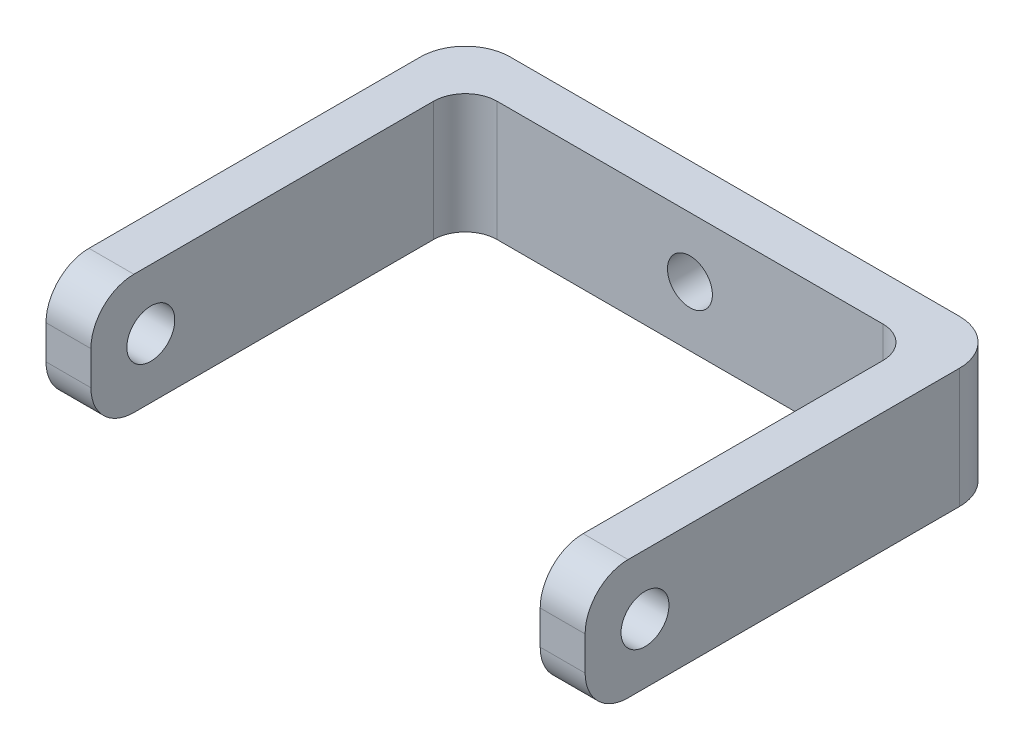
from build123d import *

# Parameters (mm, degrees)
BOSS_EXTRUDE1_DEPTH     = 8
CUT_EXTRUDE1_DEPTH      = 1
CUT_EXTRUDE1_DEPTH_BACK = 37
CUT_EXTRUDE2_DEPTH      = 1
CUT_EXTRUDE2_DEPTH_BACK = 37
CUT_EXTRUDE6_DEPTH      = 5


with BuildPart() as part:
    # Sketch1 → Boss-Extrude1 (new body)
    with BuildSketch(Plane(origin=(0, 0, 0), x_dir=(1, 0, 0), z_dir=(0, 1, 0))):
        with BuildLine():
            Line((-3, 0), (0, 0))
            Line((0, 0), (0, 22))
            ThreePointArc((0, 22), (-2.121320344, 22.878679656), (-3, 25))
            Line((-3, 25), (-3, 0))
        make_face()
        with BuildLine():
            ThreePointArc((-3, 25), (-2.121320344, 22.878679656), (0, 22))
            Line((0, 22), (0, 22.878679656))
            Line((0, 22.878679656), (0, 25))
            Line((0, 25), (-2.121320344, 27.121320344))
            ThreePointArc((-2.121320344, 27.121320344), (-2.771638598, 26.148050297), (-3, 25))
        make_face()
        with BuildLine():
            ThreePointArc((0, 28), (-1.148050297, 27.771638598), (-2.121320344, 27.121320344))
            Line((-2.121320344, 27.121320344), (0, 25))
            Line((0, 25), (2.121320344, 25))
            Line((2.121320344, 25), (3, 25))
            ThreePointArc((3, 25), (2.121320344, 27.121320344), (0, 28))
        make_face()
        with BuildLine():
            Line((30, 28), (0, 28))
            ThreePointArc((0, 28), (2.121320344, 27.121320344), (3, 25))
            Line((3, 25), (27, 25))
            ThreePointArc((27, 25), (27.878679656, 27.121320344), (30, 28))
        make_face()
        with BuildLine():
            Line((2.121320344, 25), (0, 25))
            Line((0, 25), (0.621320344, 24.378679656))
            ThreePointArc((0.621320344, 24.378679656), (1.309526193, 24.838524104), (2.121320344, 25))
        make_face()
        with BuildLine():
            Line((0, 25), (0, 22.878679656))
            ThreePointArc((0, 22.878679656), (0.161475896, 23.690473807), (0.621320344, 24.378679656))
            Line((0.621320344, 24.378679656), (0, 25))
        make_face()
        with BuildLine():
            Line((27.878679656, 25), (30, 25))
            Line((30, 25), (32.121320344, 27.121320344))
            ThreePointArc((32.121320344, 27.121320344), (31.148050297, 27.771638598), (30, 28))
            ThreePointArc((30, 28), (27.878679656, 27.121320344), (27, 25))
            Line((27, 25), (27.878679656, 25))
        make_face()
        with BuildLine():
            Line((29.378679656, 24.378679656), (30, 25))
            Line((30, 25), (27.878679656, 25))
            ThreePointArc((27.878679656, 25), (28.690473807, 24.838524104), (29.378679656, 24.378679656))
        make_face()
        with BuildLine():
            ThreePointArc((29.378679656, 24.378679656), (29.838524104, 23.690473807), (30, 22.878679656))
            Line((30, 22.878679656), (30, 25))
            Line((30, 25), (29.378679656, 24.378679656))
        make_face()
        with BuildLine():
            Line((30, 22.878679656), (30, 22))
            ThreePointArc((30, 22), (32.121320344, 22.878679656), (33, 25))
            ThreePointArc((33, 25), (32.771638598, 26.148050297), (32.121320344, 27.121320344))
            Line((32.121320344, 27.121320344), (30, 25))
            Line((30, 25), (30, 22.878679656))
        make_face()
        with BuildLine():
            Line((30, 22), (30, 0))
            Line((30, 0), (33, 0))
            Line((33, 0), (33, 25))
            ThreePointArc((33, 25), (32.121320344, 22.878679656), (30, 22))
        make_face()
    extrude(amount=BOSS_EXTRUDE1_DEPTH)

    # Sketch2 → Cut-Extrude1 (cut, two sides)
    with BuildSketch(Plane.ZY.offset(3)) as cut_extrude1_sk:
        with BuildLine():
            ThreePointArc((-5.13137085, 5.13137085), (-5.13137085, 2.86862915), (-2.86862915, 2.86862915))
            Line((-2.86862915, 2.86862915), (-5.13137085, 5.13137085))
        make_face()
        with BuildLine():
            Line((-5.13137085, 5.13137085), (-2.86862915, 2.86862915))
            ThreePointArc((-2.86862915, 2.86862915), (-2.521792748, 3.387706508), (-2.4, 4))
            ThreePointArc((-2.4, 4), (-3.387706508, 5.478207252), (-5.13137085, 5.13137085))
        make_face()
    extrude(amount=CUT_EXTRUDE1_DEPTH, mode=Mode.SUBTRACT)
    extrude(cut_extrude1_sk.sketch, amount=-CUT_EXTRUDE1_DEPTH_BACK, mode=Mode.SUBTRACT)

    # Sketch3 → Cut-Extrude2 (cut, two sides)
    with BuildSketch(Plane.ZY.offset(3)) as cut_extrude2_sk:
        with BuildLine():
            Line((0, 0), (-2.868629152, 0))
            Line((-2.86862915, 0), (-2.86862915, -3.234663016))
            ThreePointArc((-2.86862915, -3.234663016), (2.247050128, -1.115679278), (4.366033866, 4))
            ThreePointArc((4.366033866, 4), (2.247050128, 9.115679278), (-2.86862915, 11.234663016))
            Line((-2.86862915, 11.234663016), (-2.86862915, 8))
            Line((-2.86862915, 8), (0, 8))
            Line((0, 8), (0, 5.13137085))
            Line((0, 5.13137085), (0, 2.86862915))
            Line((0, 2.86862915), (0, 0))
        make_face()
        with BuildLine():
            ThreePointArc((0, 2.86862915), (-0.840202026, 0.840202025), (-2.868629152, 0))
            Line((-2.868629152, 0), (0, 0))
            Line((0, 0), (0, 2.86862915))
        make_face()
        with BuildLine():
            Line((0, 8), (-2.86862915, 8))
            ThreePointArc((-2.86862915, 8), (-0.840202025, 7.159797975), (0, 5.13137085))
            Line((0, 5.13137085), (0, 8))
        make_face()
    extrude(amount=CUT_EXTRUDE2_DEPTH, mode=Mode.SUBTRACT)
    extrude(cut_extrude2_sk.sketch, amount=-CUT_EXTRUDE2_DEPTH_BACK, mode=Mode.SUBTRACT)

    # Sketch4 → Cut-Extrude6 (cut)
    with BuildSketch(Plane(origin=(0, 0, -28), x_dir=(-1, 0, 0), z_dir=(0, 0, -1))):
        with BuildLine():
            ThreePointArc((-13.5, 4), (-13.512715795, 4.194899187), (-13.550647591, 4.386493976))
            Line((-13.550647591, 4.386493976), (-16.449352409, 3.613506024))
            ThreePointArc((-16.449352409, 3.613506024), (-14.805100813, 2.512715795), (-13.5, 4))
        make_face()
        with BuildLine():
            Line((-16.449352409, 3.613506024), (-13.550647591, 4.386493976))
            ThreePointArc((-13.550647591, 4.386493976), (-15.386493976, 5.449352409), (-16.449352409, 3.613506024))
        make_face()
    extrude(amount=-CUT_EXTRUDE6_DEPTH, mode=Mode.SUBTRACT)


solid = part.part
